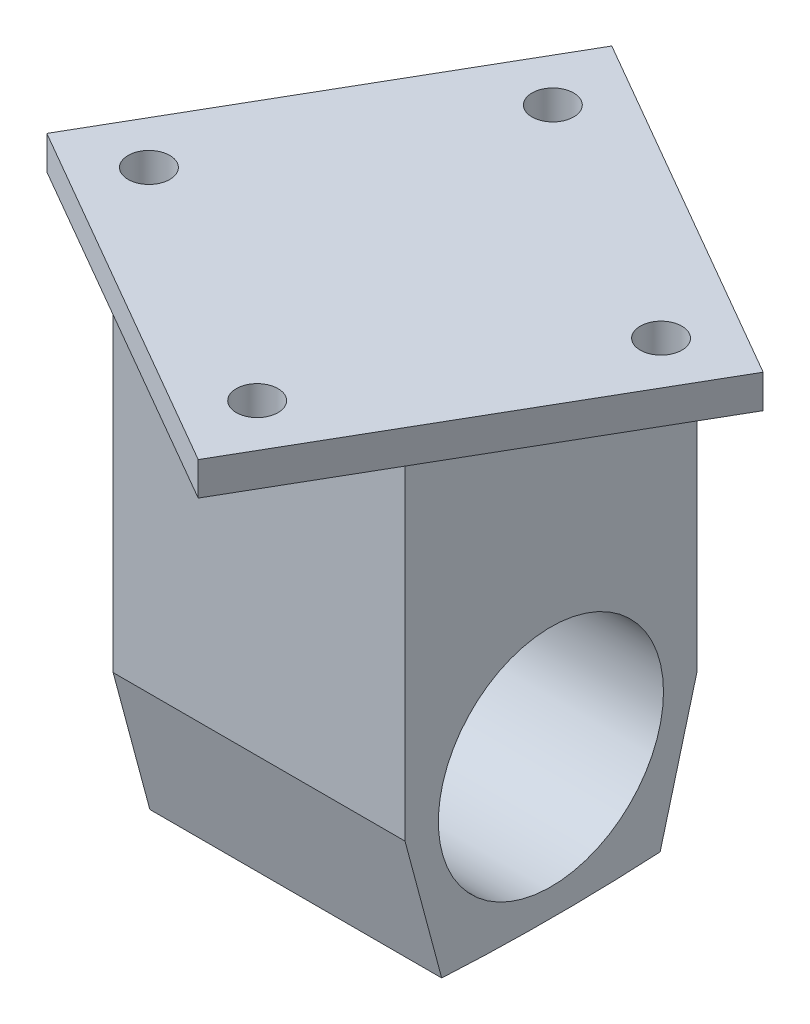
from build123d import *

# Parameters (mm, degrees)
SKETCH1_W           = 44.45
SKETCH1_H           = 44.45
BOSS_EXTRUDE1_DEPTH = 50.292
BOSS_EXTRUDE2_DEPTH = 44.45
SKETCH3_R           = 17.145
CUT_EXTRUDE1_DEPTH  = 127
BOSS_EXTRUDE3_DEPTH = 5.08
SKETCH5_R           = 3.175
CUT_EXTRUDE2_DEPTH  = 77.68803402


with BuildPart() as part:
    # Sketch1 → Boss-Extrude1 (new body)
    with BuildSketch(Plane(origin=(0, 0, 0), x_dir=(1, 0, 0), z_dir=(0, 1, 0))):
        Rectangle(SKETCH1_W, SKETCH1_H)
    extrude(amount=BOSS_EXTRUDE1_DEPTH)

    # Sketch2 → Boss-Extrude2 (add)
    with BuildSketch(Plane(origin=(22.225, 0, 0), x_dir=(0, 0, -1), z_dir=(1, 0, 0))):
        with BuildLine():
            Line((-22.225, 0), (-16.637096816, -20.85433859))
            ThreePointArc((-16.637096816, -20.85433859), (0, -21.31603402), (16.637096816, -20.85433859))
            Line((16.637096816, -20.85433859), (22.225, 0))
            Line((22.225, 0), (-22.225, 0))
        make_face()
    extrude(amount=-BOSS_EXTRUDE2_DEPTH)

    # Sketch3 → Cut-Extrude1 (cut)
    with BuildSketch(Plane(origin=(22.225, 0, 0), x_dir=(0, 0, -1), z_dir=(1, 0, 0))):
        Circle(SKETCH3_R)
    extrude(amount=-CUT_EXTRUDE1_DEPTH, mode=Mode.SUBTRACT)

    # Sketch4 → Boss-Extrude3 (add)
    with BuildSketch(Plane(origin=(0, 50.292, 0), x_dir=(1, 0, 0), z_dir=(0, 1, 0))):
        Polygon((43.024336118, 11.528336118), (11.528336118, -43.024336118), (-43.024336118, -11.528336118), (-11.528336118, 43.024336118), align=None)
    extrude(amount=BOSS_EXTRUDE3_DEPTH)

    # Sketch5 → Cut-Extrude2 (cut, through all)
    with BuildSketch(Plane(origin=(0, 55.372, 0), x_dir=(1, 0, 0), z_dir=(0, 1, 0))):
        with Locations((30.757078124, 8.241334245)):
            Circle(SKETCH5_R)
        with Locations((8.241334245, -30.757078124)):
            Circle(SKETCH5_R)
        with Locations((-8.241334245, 30.757078124)):
            Circle(SKETCH5_R)
        with Locations((-30.757078124, -8.241334245)):
            Circle(SKETCH5_R)
    extrude(amount=-CUT_EXTRUDE2_DEPTH, mode=Mode.SUBTRACT)


solid = part.part
